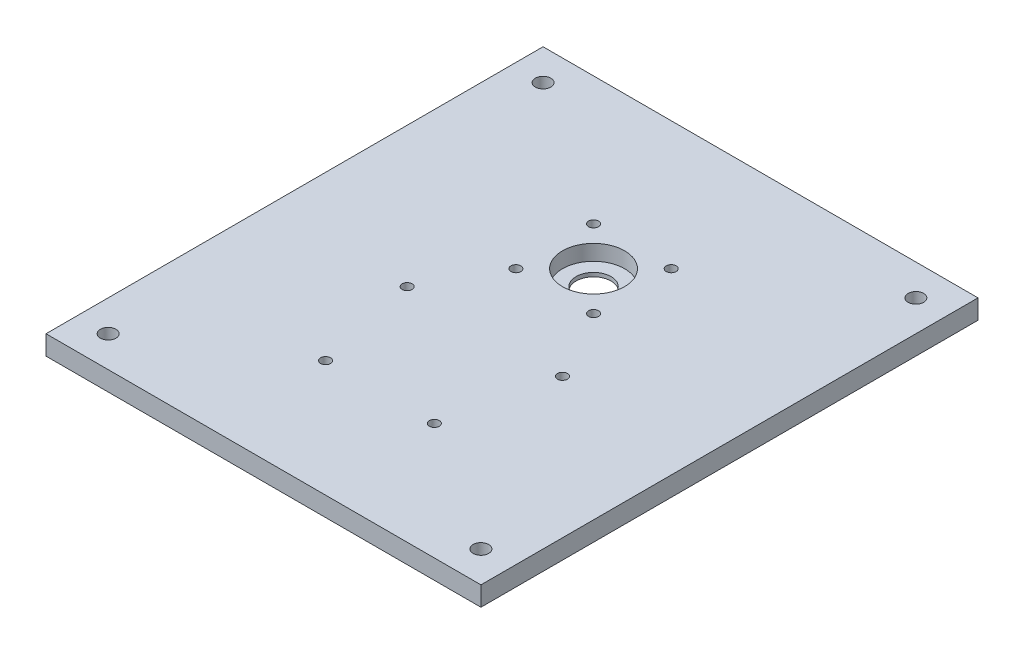
from build123d import *

# Parameters (mm, degrees)
SKETCH1_W               = 355.6
SKETCH1_H               = 406.4
BOSS_EXTRUDE1_DEPTH     = 15.875
SKETCH2_R               = 6.35
CUT_EXTRUDE1_DEPTH      = 16.875
MIRROR2_COPY_1_SKETCH_R = 6.35
MIRROR2_COPY_1_DEPTH    = 16.875
SKETCH3_R               = 14.2875
SKETCH3_R_2             = 4.064
CUT_EXTRUDE2_DEPTH      = 16.875
SKETCH4_R               = 25.4
CUT_EXTRUDE3_DEPTH      = 12.7
SKETCH5_R               = 6.35
CUT_EXTRUDE4_DEPTH      = 8.89


with BuildPart() as part:
    # Sketch1 → Boss-Extrude1 (new body)
    with BuildSketch(Plane(origin=(0, 0, 0), x_dir=(1, 0, 0), z_dir=(0, 1, 0))):
        Rectangle(SKETCH1_W, SKETCH1_H)
    extrude(amount=BOSS_EXTRUDE1_DEPTH)

    # Sketch2 → Cut-Extrude1 (cut, through all)
    with BuildSketch(Plane(origin=(0, 15.875, 0), x_dir=(1, 0, 0), z_dir=(0, 1, 0))):
        with Locations((-152.4, 177.8)):
            Circle(SKETCH2_R)
    cut_extrude1 = extrude(amount=-CUT_EXTRUDE1_DEPTH, mode=Mode.SUBTRACT)

    # Mirror1: Cut-Extrude1 across plane
    add(cut_extrude1.mirror(Plane.ZY), mode=Mode.SUBTRACT)

    # Mirror2: Cut-Extrude1 across plane
    add(cut_extrude1.mirror(Plane(origin=(0, 0, 0), x_dir=(1, 0, 0), z_dir=(0, 0, -1))), mode=Mode.SUBTRACT)

    # Mirror2 copy 1 sketch → Mirror2 copy 1 (cut, through all)
    with BuildSketch(Plane(origin=(0, 15.875, 0), x_dir=(-1, 0, 0), z_dir=(0, 1, 0))):
        with Locations((-152.4, 177.8)):
            Circle(MIRROR2_COPY_1_SKETCH_R)
    extrude(amount=-MIRROR2_COPY_1_DEPTH, mode=Mode.SUBTRACT)

    # Sketch3 → Cut-Extrude2 (cut, through all)
    with BuildSketch(Plane(origin=(0, 15.875, 0), x_dir=(1, 0, 0), z_dir=(0, 1, 0))):
        with Locations((0, 66.675)):
            Circle(SKETCH3_R)
        with Locations((-63.5, -22.225)):
            Circle(SKETCH3_R_2)
        with Locations((63.5, -22.225)):
            Circle(SKETCH3_R_2)
        with Locations((44.45, -107.95)):
            Circle(SKETCH3_R_2)
        with Locations((-44.45, -107.95)):
            Circle(SKETCH3_R_2)
        with Locations((-31.75, 98.425)):
            Circle(SKETCH3_R_2)
        with Locations((-31.75, 34.925)):
            Circle(SKETCH3_R_2)
        with Locations((31.75, 98.425)):
            Circle(SKETCH3_R_2)
        with Locations((31.75, 34.925)):
            Circle(SKETCH3_R_2)
    extrude(amount=-CUT_EXTRUDE2_DEPTH, mode=Mode.SUBTRACT)

    # Sketch4 → Cut-Extrude3 (cut)
    with BuildSketch(Plane(origin=(0, 15.875, 0), x_dir=(1, 0, 0), z_dir=(0, 1, 0))):
        with Locations((0, 66.675)):
            Circle(SKETCH4_R)
    extrude(amount=-CUT_EXTRUDE3_DEPTH, mode=Mode.SUBTRACT)

    # Sketch5 → Cut-Extrude4 (cut)
    with BuildSketch(Plane.XZ):
        with Locations((-31.75, -98.425)):
            Circle(SKETCH5_R)
        with Locations((31.75, -98.425)):
            Circle(SKETCH5_R)
        with Locations((31.75, -34.925)):
            Circle(SKETCH5_R)
        with Locations((-31.75, -34.925)):
            Circle(SKETCH5_R)
        with Locations((-63.5, 22.225)):
            Circle(SKETCH5_R)
        with Locations((63.5, 22.225)):
            Circle(SKETCH5_R)
        with Locations((44.45, 107.95)):
            Circle(SKETCH5_R)
        with Locations((-44.45, 107.95)):
            Circle(SKETCH5_R)
    extrude(amount=-CUT_EXTRUDE4_DEPTH, mode=Mode.SUBTRACT)


solid = part.part
